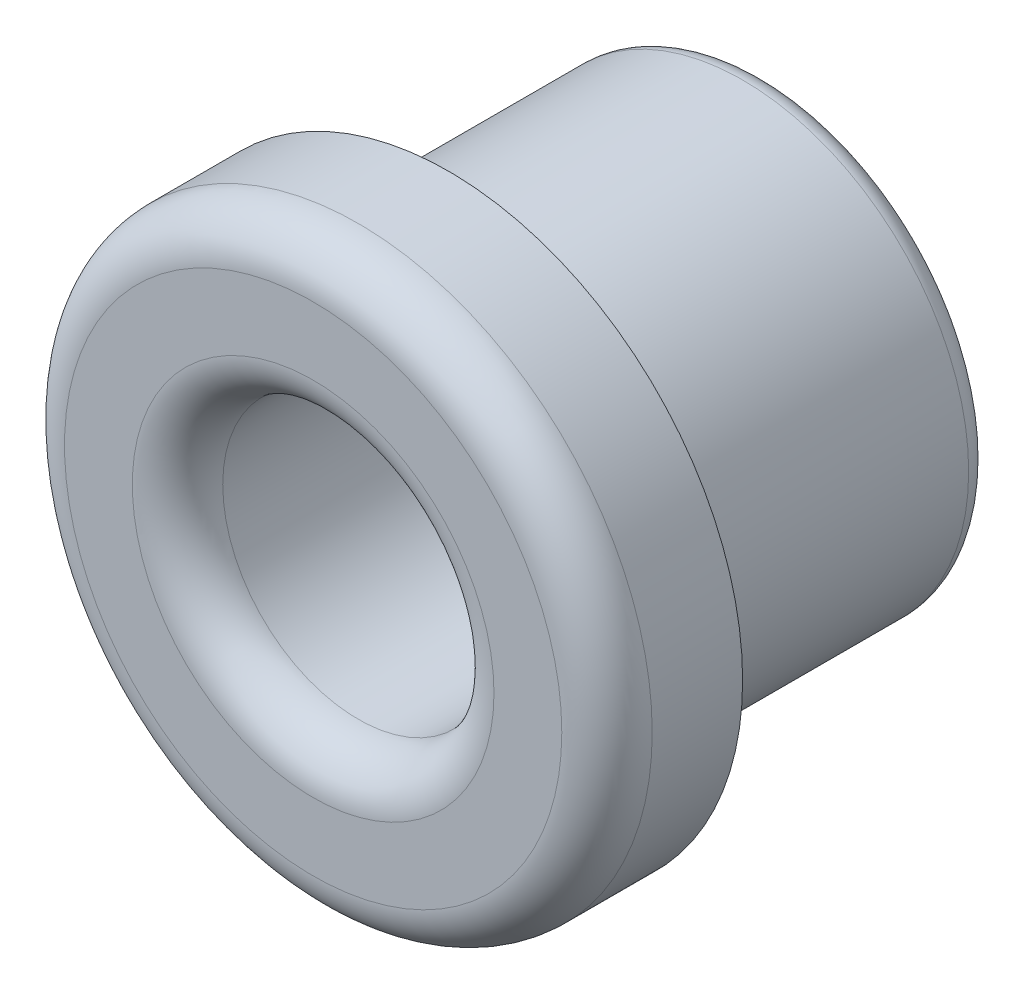
from build123d import *

# Parameters (mm, degrees)
SKETCH1_R           = 5
SKETCH1_R_2         = 3
BOSS_EXTRUDE1_DEPTH = 7
SKETCH2_R           = 6.5
SKETCH2_R_2         = 3
BOSS_EXTRUDE2_DEPTH = 3
FILLET1_R           = 1
FILLET2_R           = 0.5


with BuildPart() as part:
    # Sketch1 → Boss-Extrude1 (new body)
    with BuildSketch(Plane.XY):
        Circle(SKETCH1_R)
        Circle(SKETCH1_R_2, mode=Mode.SUBTRACT)
    extrude(amount=BOSS_EXTRUDE1_DEPTH)

    # Sketch2 → Boss-Extrude2 (add)
    with BuildSketch(Plane.XY.offset(7)):
        Circle(SKETCH2_R)
        Circle(SKETCH2_R_2, mode=Mode.SUBTRACT)
    extrude(amount=BOSS_EXTRUDE2_DEPTH)

    # Fillet1
    fillet1_edges = [part.edges().sort_by_distance(p)[0] for p in [
        (-6.5, 0, 10),
        (-3, 0, 10),
    ]]
    fillet(fillet1_edges, radius=FILLET1_R)

    # Fillet2
    fillet2_edges = [part.edges().sort_by_distance(p)[0] for p in [
        (-5, 0, 0),
    ]]
    fillet(fillet2_edges, radius=FILLET2_R)


solid = part.part
